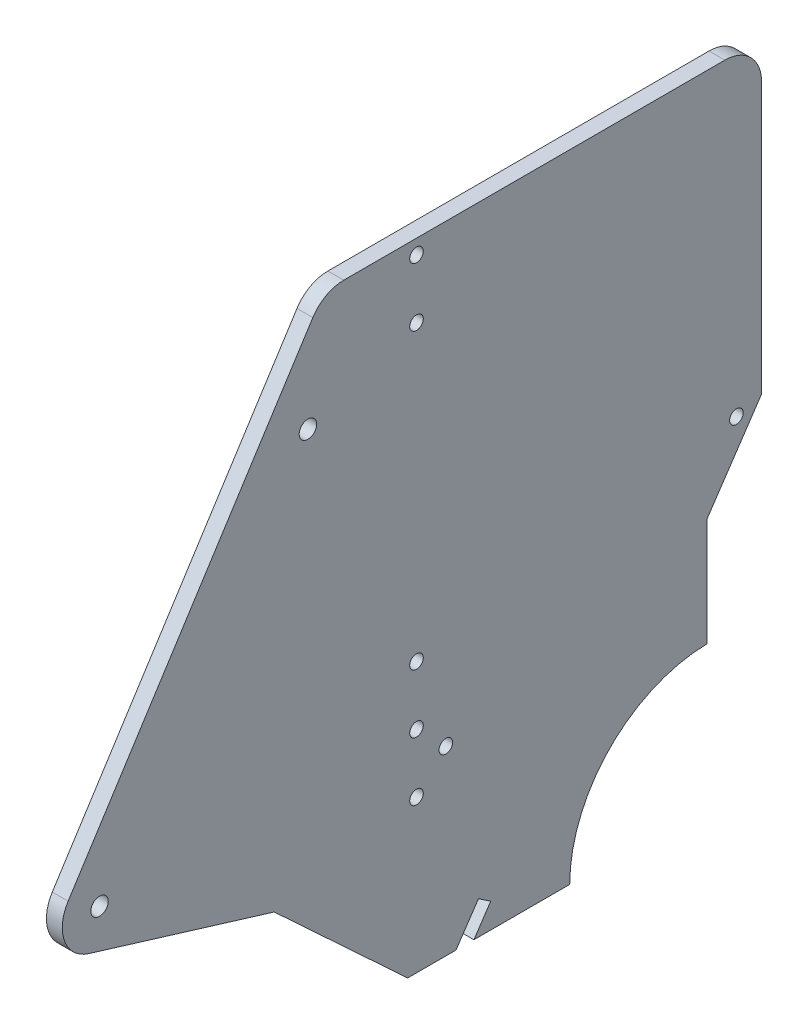
from build123d import *

# Parameters (mm, degrees)
SKETCH2_R           = 2.38125
SKETCH2_R_2         = 1.85
BOSS_EXTRUDE1_DEPTH = 4.318


with BuildPart() as part:
    # Sketch2 → Boss-Extrude1 (new body)
    with BuildSketch(Plane(origin=(0, 0, 0), x_dir=(0, 0, -1), z_dir=(1, 0, 0))):
        with BuildLine():
            Line((-115.889220019, 171.954), (-219.799081889, 171.954))
            ThreePointArc((-219.799081889, 171.954), (-224.603807745, 170.72409746), (-228.226664693, 167.336921891))
            Line((-228.226664693, 167.336921891), (-294.933682845, 62.899419265))
            ThreePointArc((-294.933682845, 62.899419265), (-295.905218473, 53.919072951), (-289.341021135, 47.714089896))
            Line((-289.341021135, 47.714089896), (-238.759677477, 32.254))
            Line((-238.759677477, 32.254), (-202.359677477, -1.524))
            Line((-202.359677477, -1.524), (-189.18491037, -1.524))
            Line((-189.18491037, -1.524), (-183.068077693, 7.544577378))
            Line((-183.068077693, 7.544577378), (-179.720203102, 5.286407453))
            Line((-179.720203102, 5.286407453), (-184.313880932, -1.524))
            Line((-184.313880932, -1.524), (-158.188157254, -1.524))
            ThreePointArc((-158.188157254, -1.524), (-147.265506636, 25.180552261), (-120.759258716, 36.576))
            Line((-120.759258716, 36.576), (-120.759258716, 66.032))
            Line((-120.759258716, 66.032), (-105.889220019, 88.077738973))
            Line((-105.889220019, 88.077738973), (-105.889220019, 161.954))
            ThreePointArc((-105.889220019, 161.954), (-108.818152207, 169.025067812), (-115.889220019, 171.954))
        make_face()
        with Locations((-286.371258716, 57.430370624)):
            Circle(SKETCH2_R, mode=Mode.SUBTRACT)
        with Locations((-229.557259723, 141.660587995)):
            Circle(SKETCH2_R, mode=Mode.SUBTRACT)
        with Locations((-112.732319414, 86.216867448)):
            Circle(SKETCH2_R_2, mode=Mode.SUBTRACT)
        with Locations((-199.955990958, 72)):
            Circle(SKETCH2_R_2, mode=Mode.SUBTRACT)
        with Locations((-199.955990958, 152)):
            Circle(SKETCH2_R_2, mode=Mode.SUBTRACT)
        with Locations((-199.955990958, 168)):
            Circle(SKETCH2_R_2, mode=Mode.SUBTRACT)
        with Locations((-199.955990958, 40)):
            Circle(SKETCH2_R_2, mode=Mode.SUBTRACT)
        with Locations((-191.955990958, 48)):
            Circle(SKETCH2_R_2, mode=Mode.SUBTRACT)
        with Locations((-199.955990958, 56)):
            Circle(SKETCH2_R_2, mode=Mode.SUBTRACT)
    extrude(amount=BOSS_EXTRUDE1_DEPTH)


solid = part.part
